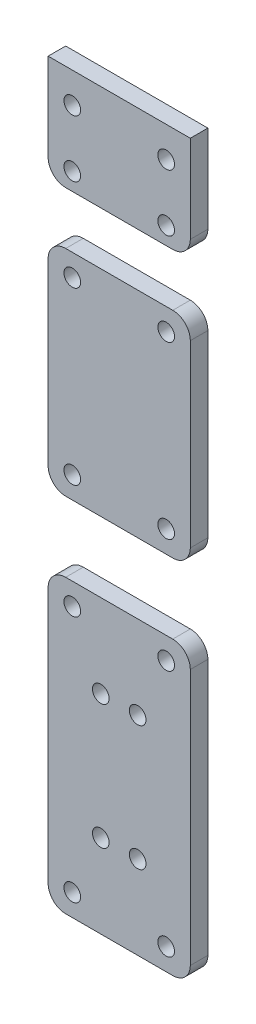
from build123d import *

# Parameters (mm, degrees)
SKETCH1_R           = 0.95
SKETCH1_W           = 4.2
SKETCH1_H           = 8
SKETCH1_W_2         = 8.2
SKETCH1_H_2         = 6
BOSS_EXTRUDE1_DEPTH = 2
SKETCH2_W           = 10.7
SKETCH2_H           = 6
SKETCH2_W_2         = 8.2
SKETCH2_H_2         = 8
SKETCH2_H_3         = 12
CUT_EXTRUDE1_DEPTH  = 2


with BuildPart() as part:
    # Sketch1 → Boss-Extrude1 (new body)
    with BuildSketch(Plane.XY):
        with BuildLine():
            Line((16.2, 109.64), (0, 109.64))
            Line((0, 109.64), (0, 99.66))
            ThreePointArc((0, 99.66), (0.585786438, 98.245786438), (2, 97.66))
            Line((2, 97.66), (2.75, 97.66))
            Line((2.75, 97.66), (2.75, 91.66))
            Line((2.75, 91.66), (2, 91.66))
            ThreePointArc((2, 91.66), (0.585786438, 91.074213562), (0, 89.66))
            Line((0, 89.66), (0, 69.21))
            ThreePointArc((0, 69.21), (0.585786438, 67.795786438), (2, 67.21))
            Line((2, 67.21), (4, 67.21))
            Line((4, 67.21), (4, 59.21))
            Line((4, 59.21), (2, 59.21))
            ThreePointArc((2, 59.21), (0.585786438, 58.624213562), (0, 57.21))
            Line((0, 57.21), (0, 28))
            ThreePointArc((0, 28), (0.585786438, 26.585786438), (2, 26))
            Line((2, 26), (4, 26))
            Line((4, 26), (4, 14))
            Line((4, 14), (6, 14))
            Line((6, 14), (6, 26))
            Line((6, 26), (10.2, 26))
            Line((10.2, 26), (10.2, 14))
            Line((10.2, 14), (12.2, 14))
            Line((12.2, 14), (12.2, 26))
            Line((12.2, 26), (14.2, 26))
            ThreePointArc((14.2, 26), (15.614213562, 26.585786438), (16.2, 28))
            Line((16.2, 28), (16.2, 57.21))
            ThreePointArc((16.2, 57.21), (15.614213562, 58.624213562), (14.2, 59.21))
            Line((14.2, 59.21), (12.2, 59.21))
            Line((12.2, 59.21), (12.2, 67.21))
            Line((12.2, 67.21), (14.2, 67.21))
            ThreePointArc((14.2, 67.21), (15.614213562, 67.795786438), (16.2, 69.21))
            Line((16.2, 69.21), (16.2, 89.66))
            ThreePointArc((16.2, 89.66), (15.614213562, 91.074213562), (14.2, 91.66))
            Line((14.2, 91.66), (13.45, 91.66))
            Line((13.45, 91.66), (13.45, 97.66))
            Line((13.45, 97.66), (14.2, 97.66))
            ThreePointArc((14.2, 97.66), (15.614213562, 98.245786438), (16.2, 99.66))
            Line((16.2, 99.66), (16.2, 109.64))
        make_face()
        with Locations((13.45, 56.71)):
            Circle(SKETCH1_R, mode=Mode.SUBTRACT)
        with Locations((10.2, 49.71)):
            Circle(SKETCH1_R, mode=Mode.SUBTRACT)
        with Locations((13.45, 106.16)):
            Circle(SKETCH1_R, mode=Mode.SUBTRACT)
        with Locations((2.75, 99.66)):
            Circle(SKETCH1_R, mode=Mode.SUBTRACT)
        with Locations((6, 49.71)):
            Circle(SKETCH1_R, mode=Mode.SUBTRACT)
        with Locations((2.75, 28.5)):
            Circle(SKETCH1_R, mode=Mode.SUBTRACT)
        with Locations((2.75, 89.16)):
            Circle(SKETCH1_R, mode=Mode.SUBTRACT)
        with Locations((2.75, 56.71)):
            Circle(SKETCH1_R, mode=Mode.SUBTRACT)
        with Locations((13.45, 89.16)):
            Circle(SKETCH1_R, mode=Mode.SUBTRACT)
        with Locations((13.45, 99.66)):
            Circle(SKETCH1_R, mode=Mode.SUBTRACT)
        with Locations((13.45, 69.71)):
            Circle(SKETCH1_R, mode=Mode.SUBTRACT)
        with Locations((6, 35.5)):
            Circle(SKETCH1_R, mode=Mode.SUBTRACT)
        with Locations((2.75, 106.16)):
            Circle(SKETCH1_R, mode=Mode.SUBTRACT)
        with Locations((10.2, 35.5)):
            Circle(SKETCH1_R, mode=Mode.SUBTRACT)
        with Locations((2.75, 69.71)):
            Circle(SKETCH1_R, mode=Mode.SUBTRACT)
        with Locations((13.45, 28.5)):
            Circle(SKETCH1_R, mode=Mode.SUBTRACT)
        with Locations((8.1, 63.21)):
            Rectangle(SKETCH1_W, SKETCH1_H, mode=Mode.SUBTRACT)
        with Locations((8.1, 94.66)):
            Rectangle(SKETCH1_W_2, SKETCH1_H_2, mode=Mode.SUBTRACT)
    extrude(amount=BOSS_EXTRUDE1_DEPTH)

    # Sketch2 → Cut-Extrude1 (cut)
    with BuildSketch(Plane(origin=(0, 0, 0), x_dir=(-1, 0, 0), z_dir=(0, 0, -1))):
        with Locations((-8.1, 94.66)):
            Rectangle(SKETCH2_W, SKETCH2_H)
        with Locations((-8.1, 63.21)):
            Rectangle(SKETCH2_W_2, SKETCH2_H_2)
        with Locations((-8.1, 20)):
            Rectangle(SKETCH2_W_2, SKETCH2_H_3)
    extrude(amount=-CUT_EXTRUDE1_DEPTH, mode=Mode.SUBTRACT)


solid = part.part
